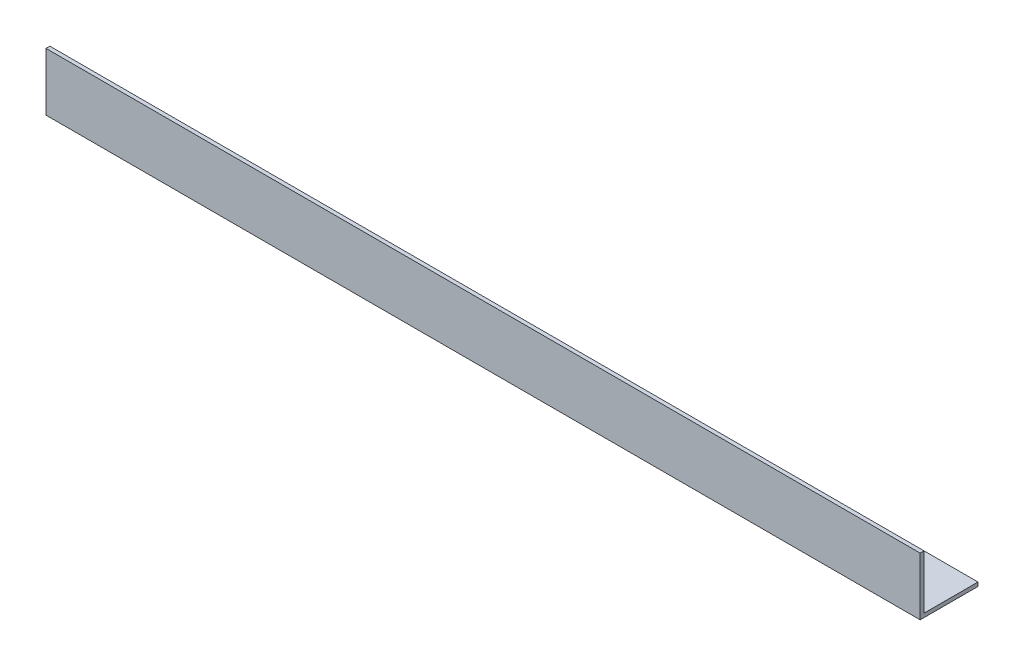
from build123d import *

# Parameters (mm, degrees)
EXTRUDE_1_DEPTH = 680


with BuildPart() as part:
    # Эскиз1 → Вытянуть-Тонкостенный1 (new body)
    with BuildSketch(Plane(origin=(0, 0, 0), x_dir=(0, 0, -1), z_dir=(1, 0, 0))):
        Polygon((45, 0), (0, 0), (0, 45), (3, 45), (3, 3), (45, 3), align=None)
    extrude(amount=EXTRUDE_1_DEPTH)


solid = part.part
